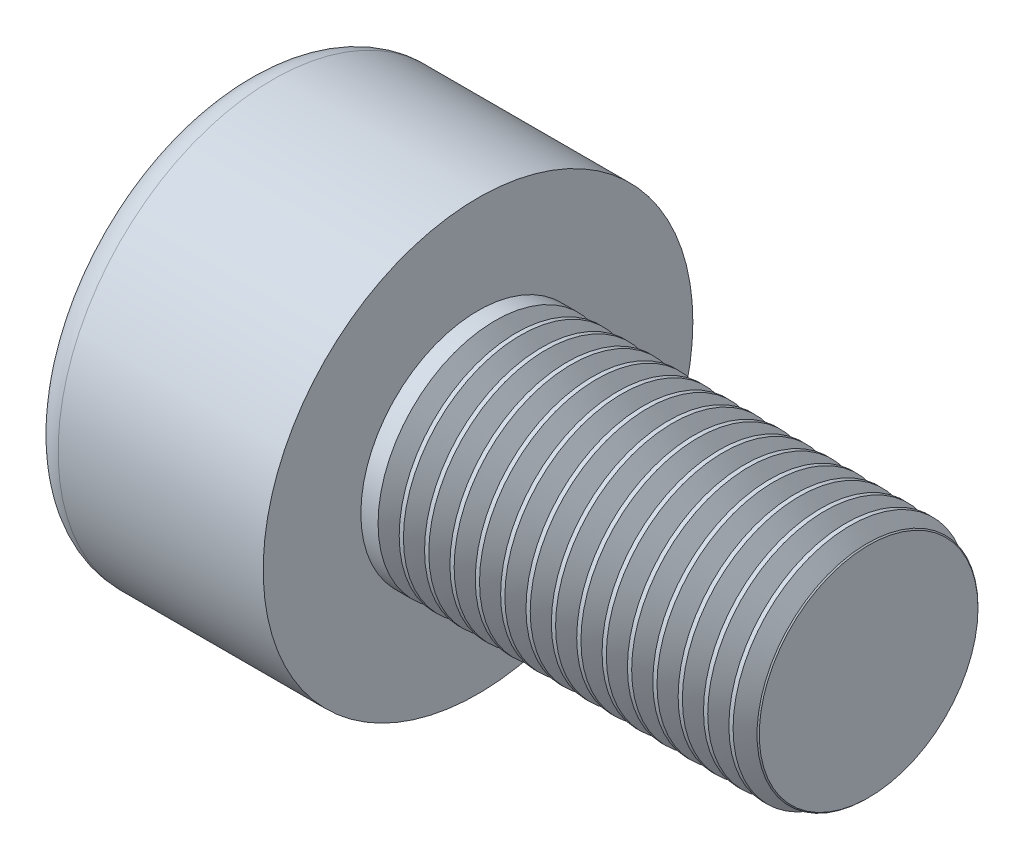
from build123d import *

# Parameters (mm, degrees)
SKETCH1_R           = 2.75
BASEHEAD_DEPTH      = 3
SKETCH2_R           = 1.5
BASEBODY_DEPTH      = 5
HEXAGONSOCKET_DEPTH = 1.3
TOPFILLET_R         = 0.375
CHAMFER1_SIZE       = 0.1
LPATTERN10_COUNT    = 15
LPATTERN10_PITCH    = 0.3246


with BuildPart() as part:
    # Sketch1 → BaseHead (new body)
    with BuildSketch(Plane(origin=(0, 0, 0), x_dir=(0, 0, -1), z_dir=(1, 0, 0))):
        Circle(SKETCH1_R)
    extrude(amount=BASEHEAD_DEPTH)

    # Sketch2 → BaseBody (add)
    with BuildSketch(Plane(origin=(3, 0, 0), x_dir=(0, 0, -1), z_dir=(1, 0, 0))):
        Circle(SKETCH2_R)
    extrude(amount=BASEBODY_DEPTH)

    # Sketch3 → HexagonSocket (cut)
    with BuildSketch(Plane(origin=(0, 0, 0), x_dir=(0, 0, -1), z_dir=(1, 0, 0))):
        Polygon((1.443375673, 0), (0.721687836, 1.25), (-0.721687836, 1.25), (-1.443375673, 0), (-0.721687836, -1.25), (0.721687836, -1.25), align=None)
    extrude(amount=HEXAGONSOCKET_DEPTH, mode=Mode.SUBTRACT)

    # Sketch4 → Cut-Revolve1 (revolve, cut)
    with BuildSketch(Plane(origin=(-4.19613823, 0.75, 0), x_dir=(-1, 0, 0), z_dir=(0, 0, 1))):
        Polygon((-5.49613823, 2), (-6.217826066, 0.75), (-5.49613823, 0.75), align=None)
    revolve(axis=Axis((0.838992387, 0, 0), (-1, 0, 0)), mode=Mode.SUBTRACT)

    # TopFillet
    topfillet_edges = [part.edges().sort_by_distance(p)[0] for p in [
        (0, 0, 2.75),
    ]]
    fillet(topfillet_edges, radius=TOPFILLET_R)

    # Chamfer1
    chamfer1_edges = [part.edges().sort_by_distance(p)[0] for p in [
        (8, 0, 1.5),
    ]]
    chamfer(chamfer1_edges, length=CHAMFER1_SIZE)

    # Sketch5 → Cut-Revolve10 (revolve, cut)
    with BuildSketch(Plane.XY):
        Polygon((7.9, 1.265740128), (8.03525, 1.5), (8.03525, 1.7705), (7.76475, 1.7705), (7.76475, 1.5), align=None)
    cut_revolve10 = revolve(axis=Axis((0, 0, 0), (1, 0, 0)), mode=Mode.SUBTRACT)

    # LPattern10: Cut-Revolve10 ×15
    with Locations(*[(-i * LPATTERN10_PITCH, 0, 0) for i in range(1, LPATTERN10_COUNT)]):
        add(cut_revolve10, mode=Mode.SUBTRACT)


solid = part.part
